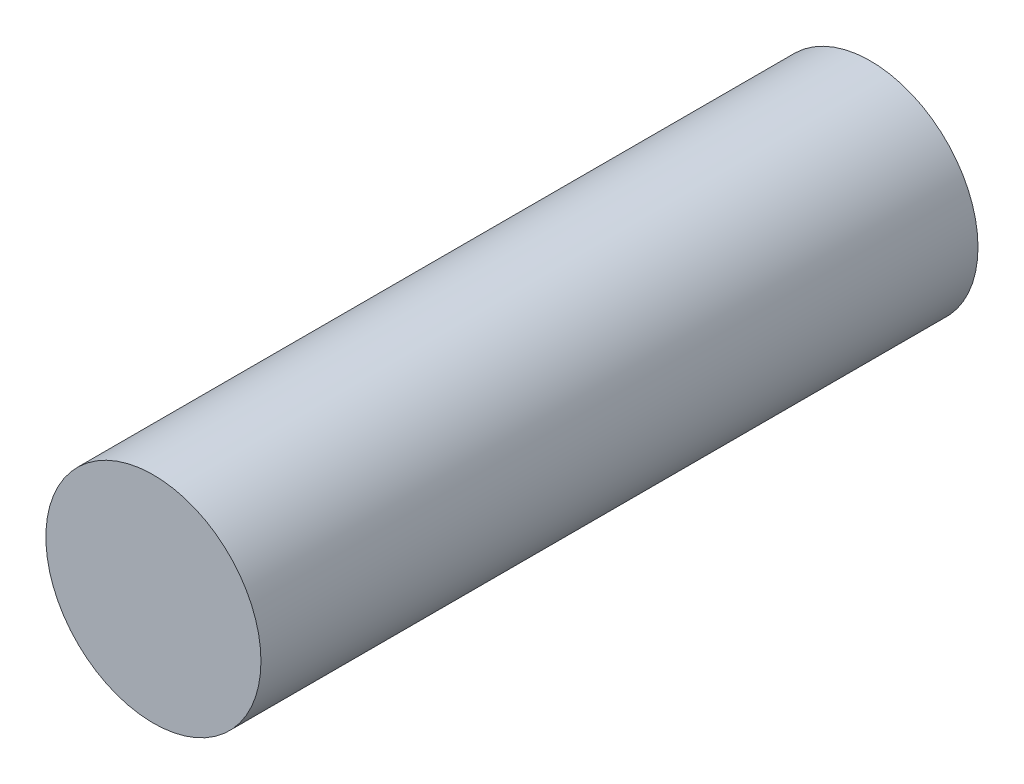
from build123d import *

# Parameters (mm, degrees)
SKETCH1_R          = 7.62
BASE_EXTRUDE_DEPTH = 50.8


with BuildPart() as part:
    # Sketch1 → Base-Extrude (new body)
    with BuildSketch(Plane.XY):
        Circle(SKETCH1_R)
    extrude(amount=BASE_EXTRUDE_DEPTH)


solid = part.part
